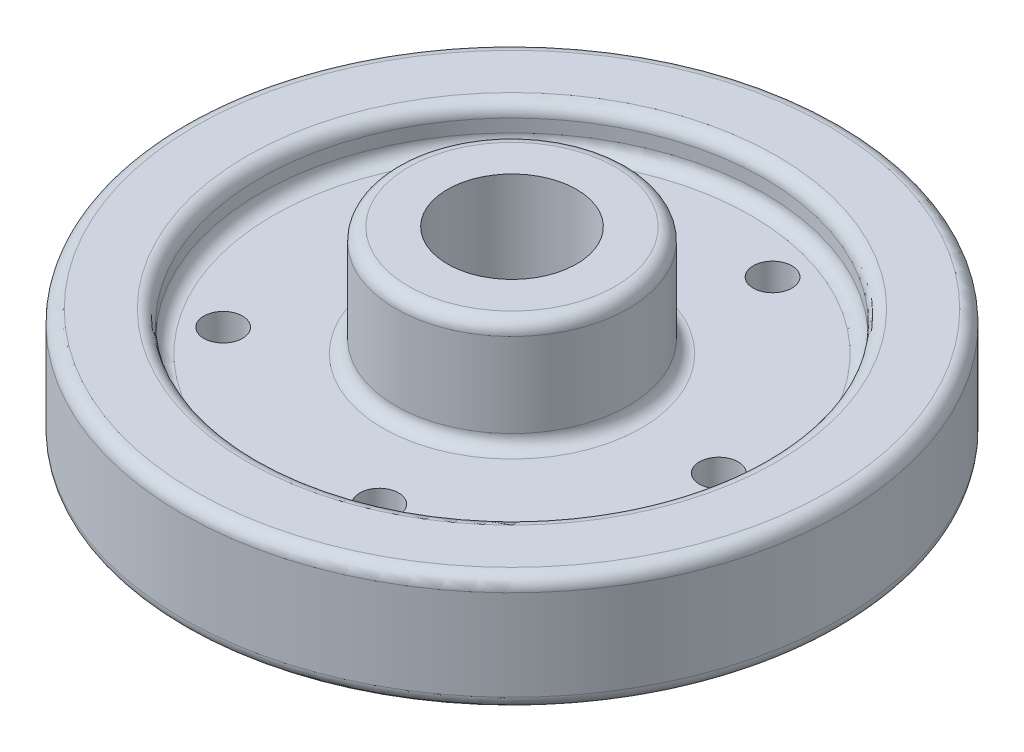
from build123d import *

# Parameters (mm, degrees)
SKETCH3_R          = 4.7625
CUT_EXTRUDE1_DEPTH = 9.525


with BuildPart() as part:
    # Sketch1 → Revolve10 (revolve)
    with BuildSketch(Plane.XY):
        with BuildLine():
            Line((15.875, 0), (15.875, 46.0502))
            Line((15.875, 46.0502), (25.4, 46.0502))
            ThreePointArc((25.4, 46.0502), (27.64506403, 45.12026403), (28.575, 42.8752))
            Line((28.575, 42.8752), (28.575, 22.225))
            ThreePointArc((28.575, 22.225), (29.50493597, 19.97993597), (31.75, 19.05))
            Line((31.75, 19.05), (58.7375, 19.05))
            ThreePointArc((58.7375, 19.05), (60.98256403, 19.97993597), (61.9125, 22.225))
            Line((61.9125, 22.225), (61.9125, 25.4))
            ThreePointArc((61.9125, 25.4), (62.84243597, 27.64506403), (65.0875, 28.575))
            Line((65.0875, 28.575), (77.7875, 28.575))
            ThreePointArc((77.7875, 28.575), (80.03256403, 27.64506403), (80.9625, 25.4))
            Line((80.9625, 25.4), (80.9625, 3.175))
            ThreePointArc((80.9625, 3.175), (80.03256403, 0.92993597), (77.7875, 0))
            Line((77.7875, 0), (65.0875, 0))
            ThreePointArc((65.0875, 0), (62.84243597, 0.92993597), (61.9125, 3.175))
            Line((61.9125, 3.175), (61.9125, 6.35))
            ThreePointArc((61.9125, 6.35), (60.98256403, 8.59506403), (58.7375, 9.525))
            Line((58.7375, 9.525), (28.575, 9.525))
            Line((28.575, 9.525), (28.575, 3.175))
            ThreePointArc((28.575, 3.175), (27.64506403, 0.92993597), (25.4, 0))
            Line((25.4, 0), (15.875, 0))
        make_face()
    revolve(axis=Axis((0, 0, 0), (0, 1, 0)))

    # Sketch3 → Cut-Extrude1 (cut)
    with BuildSketch(Plane(origin=(0, 9.525, 0), x_dir=(-1, 0, 0), z_dir=(0, -1, 0))):
        with Locations((-50.8, 0)):
            Circle(SKETCH3_R)
        with Locations((-15.698063314, 48.313671028)):
            Circle(SKETCH3_R)
        with Locations((41.098063314, 29.859490816)):
            Circle(SKETCH3_R)
        with Locations((41.098063314, -29.859490816)):
            Circle(SKETCH3_R)
        with Locations((-15.698063314, -48.313671028)):
            Circle(SKETCH3_R)
    extrude(amount=-CUT_EXTRUDE1_DEPTH, mode=Mode.SUBTRACT)


solid = part.part
